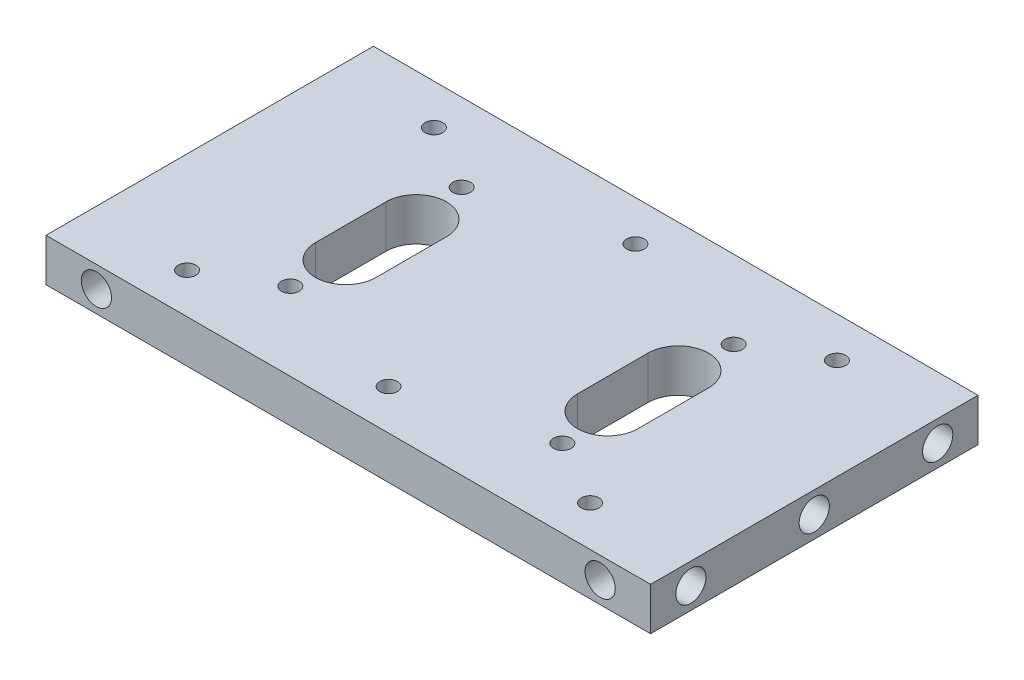
from build123d import *

# Parameters (mm, degrees)
SKETCH1_W                      = 65
SKETCH1_H                      = 8.5
BOSS_EXTRUDE1_DEPTH            = 120
F_6_0MM_DOWEL_HOLE1_AT_2_COUNT = 2
F_6_0MM_DOWEL_HOLE1_AT_2_PITCH = 24.5
F_6_0MM_DOWEL_HOLE1_AT_3_COUNT = 2
F_6_0MM_DOWEL_HOLE1_AT_3_PITCH = 49
F_6_0MM_DOWEL_HOLE2_AT_2_COUNT = 2
F_6_0MM_DOWEL_HOLE2_AT_2_PITCH = 100
CUT_EXTRUDE1_DEPTH             = 9.5
F_3_0MM_DOWEL_HOLE1_D          = 3.5


with BuildPart() as part:
    # Sketch1 → Boss-Extrude1 (new body)
    with BuildSketch(Plane(origin=(0, 0, 0), x_dir=(0, 0, -1), z_dir=(1, 0, 0))):
        Rectangle(SKETCH1_W, SKETCH1_H)
    extrude(amount=BOSS_EXTRUDE1_DEPTH)

    # Sketch3 → Ø6.0mm Dowel Hole1 (revolve, cut)
    with BuildSketch(Plane(origin=(120, 0, 24.5), x_dir=(0, 0, -1), z_dir=(0, 1, 0))):
        Polygon((0, 0), (0, 11.802581857), (3, 10), (3, 0), align=None)
    f_6_0mm_dowel_hole1 = revolve(axis=Axis((126.35, 0, 24.5), (-1, 0, 0)), mode=Mode.SUBTRACT)

    # Ø6.0mm Dowel Hole1 at 2: Ø6.0mm Dowel Hole1 ×2
    with Locations(*[(0, 0, -i * F_6_0MM_DOWEL_HOLE1_AT_2_PITCH) for i in range(1, F_6_0MM_DOWEL_HOLE1_AT_2_COUNT)]):
        add(f_6_0mm_dowel_hole1, mode=Mode.SUBTRACT)

    # Ø6.0mm Dowel Hole1 at 3: Ø6.0mm Dowel Hole1 ×2
    with Locations(*[(0, 0, -i * F_6_0MM_DOWEL_HOLE1_AT_3_PITCH) for i in range(1, F_6_0MM_DOWEL_HOLE1_AT_3_COUNT)]):
        add(f_6_0mm_dowel_hole1, mode=Mode.SUBTRACT)

    # Mirror1: Ø6.0mm Dowel Hole1 across plane
    add(f_6_0mm_dowel_hole1.mirror(Plane(origin=(60, 0, 0), x_dir=(0, 0, 1), z_dir=(1, 0, 0))), mode=Mode.SUBTRACT)

    # Mirror1 copy 1 sketch → Mirror1 copy 1 (revolve, cut)
    with BuildSketch(Plane(origin=(0, 0, 0), x_dir=(0, 0, -1), z_dir=(0, 1, 0))):
        Polygon((0, 0), (0, -11.802581857), (3, -10), (3, 0), align=None)
    revolve(axis=Axis((-6.35, 0, 0), (-1, 0, 0)), mode=Mode.SUBTRACT)

    # Mirror1 copy 2 sketch → Mirror1 copy 2 (revolve, cut)
    with BuildSketch(Plane(origin=(0, 0, -24.5), x_dir=(0, 0, -1), z_dir=(0, 1, 0))):
        Polygon((0, 0), (0, -11.802581857), (3, -10), (3, 0), align=None)
    revolve(axis=Axis((-6.35, 0, -24.5), (-1, 0, 0)), mode=Mode.SUBTRACT)

    # Sketch5 → Ø6.0mm Dowel Hole2 (revolve, cut)
    with BuildSketch(Plane(origin=(110, 0, -32.5), x_dir=(0, 1, 0), z_dir=(1, 0, 0))):
        Polygon((0, 0), (0, 9.802581857), (3, 8), (3, 0), align=None)
    f_6_0mm_dowel_hole2 = revolve(axis=Axis((110, 0, -38.85), (0, 0, 1)), mode=Mode.SUBTRACT)

    # Ø6.0mm Dowel Hole2 at 2: Ø6.0mm Dowel Hole2 ×2
    with Locations(*[(-i * F_6_0MM_DOWEL_HOLE2_AT_2_PITCH, 0, 0) for i in range(1, F_6_0MM_DOWEL_HOLE2_AT_2_COUNT)]):
        add(f_6_0mm_dowel_hole2, mode=Mode.SUBTRACT)

    # Mirror2: Ø6.0mm Dowel Hole2 across plane
    add(f_6_0mm_dowel_hole2.mirror(Plane.XY), mode=Mode.SUBTRACT)

    # Mirror2 copy 1 sketch → Mirror2 copy 1 (revolve, cut)
    with BuildSketch(Plane(origin=(10, 0, 32.5), x_dir=(0, 1, 0), z_dir=(1, 0, 0))):
        Polygon((0, 0), (0, -9.802581857), (3, -8), (3, 0), align=None)
    revolve(axis=Axis((10, 0, 38.85), (0, 0, 1)), mode=Mode.SUBTRACT)

    # Sketch6 → Cut-Extrude1 (cut, through all)
    with BuildSketch(Plane(origin=(0, 4.25, 0), x_dir=(1, 0, 0), z_dir=(0, 1, 0))):
        with BuildLine():
            Line((80, -7), (80, 7))
            ThreePointArc((80, 7), (86, 13), (92, 7))
            Line((92, 7), (92, -7))
            ThreePointArc((92, -7), (86, -13), (80, -7))
        make_face()
    cut_extrude1 = extrude(amount=-CUT_EXTRUDE1_DEPTH, mode=Mode.SUBTRACT)

    # Mirror3: Cut-Extrude1 across plane
    add(cut_extrude1.mirror(Plane(origin=(60, 0, 0), x_dir=(0, 0, 1), z_dir=(1, 0, 0))), mode=Mode.SUBTRACT)

    # Ø3.0mm Dowel Hole1 (through all)
    with Locations(Plane(origin=(0, 4.25, 0), x_dir=(1, 0, 0), z_dir=(0, 1, 0))):
        with Locations((87, -17), (87, 17), (33, 17), (33, -17), (100, -24.5), (60, -24.5), (20, -24.5), (100, 24.5), (60, 24.5), (20, 24.5)):
            Hole(F_3_0MM_DOWEL_HOLE1_D / 2)


solid = part.part
